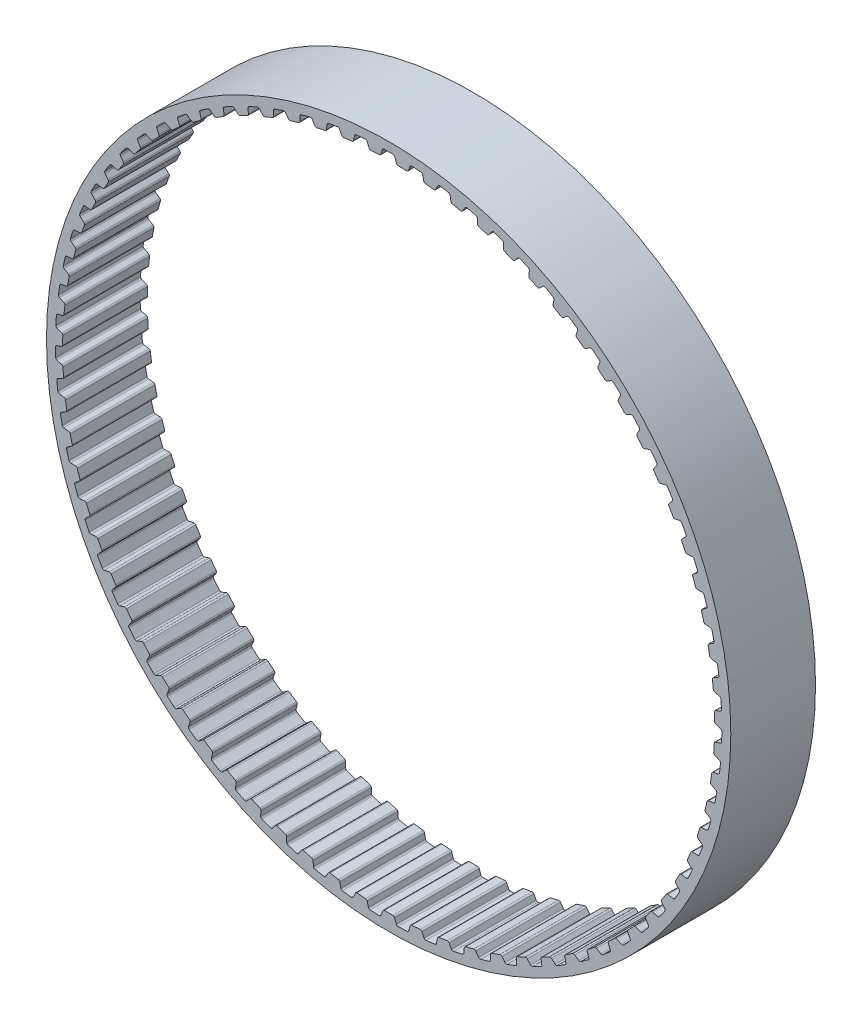
from build123d import *

# Parameters (mm, degrees)
SKETCH4_R           = 24.231360553
SKETCH4_R_2         = 23.088360553
BOSS_EXTRUDE1_DEPTH = 3
CUT_EXTRUDE1_DEPTH  = 3
CIRPATTERN1_COUNT   = 75


with BuildPart() as part:
    # Sketch4 → Boss-Extrude1 (new body, symmetric)
    with BuildSketch(Plane.XY):
        Circle(SKETCH4_R)
        Circle(SKETCH4_R_2, mode=Mode.SUBTRACT)
    extrude(amount=BOSS_EXTRUDE1_DEPTH, both=True)

    # Sketch3 → Cut-Extrude1 (cut, symmetric)
    with BuildSketch(Plane.XY):
        with BuildLine():
            Line((-0.668665559, 23.078675859), (0.668665559, 23.078675859))
            ThreePointArc((0.668665559, 23.078675859), (0.595860389, 23.104235633), (0.551288411, 23.167221611))
            Line((0.551288411, 23.167221611), (0.443967506, 23.505539967))
            ThreePointArc((0.443967506, 23.505539967), (0.398622486, 23.569104507), (0.32465967, 23.594126969))
            ThreePointArc((0.32465967, 23.594126969), (0, 23.596360553), (-0.32465967, 23.594126969))
            ThreePointArc((-0.32465967, 23.594126969), (-0.398622486, 23.569104507), (-0.443967506, 23.505539967))
            Line((-0.443967506, 23.505539967), (-0.551288411, 23.167221611))
            ThreePointArc((-0.551288411, 23.167221611), (-0.595860389, 23.104235633), (-0.668665559, 23.078675859))
        make_face()
    cut_extrude1 = extrude(amount=CUT_EXTRUDE1_DEPTH, both=True, mode=Mode.SUBTRACT)

    # CirPattern1: Cut-Extrude1 ×75 about axis
    cirpattern1_axis = Axis((0, 0, 0), (0, 0, 1))
    for i in range(1, CIRPATTERN1_COUNT):
        add(cut_extrude1.rotate(cirpattern1_axis, i * 360 / CIRPATTERN1_COUNT), mode=Mode.SUBTRACT)


solid = part.part
